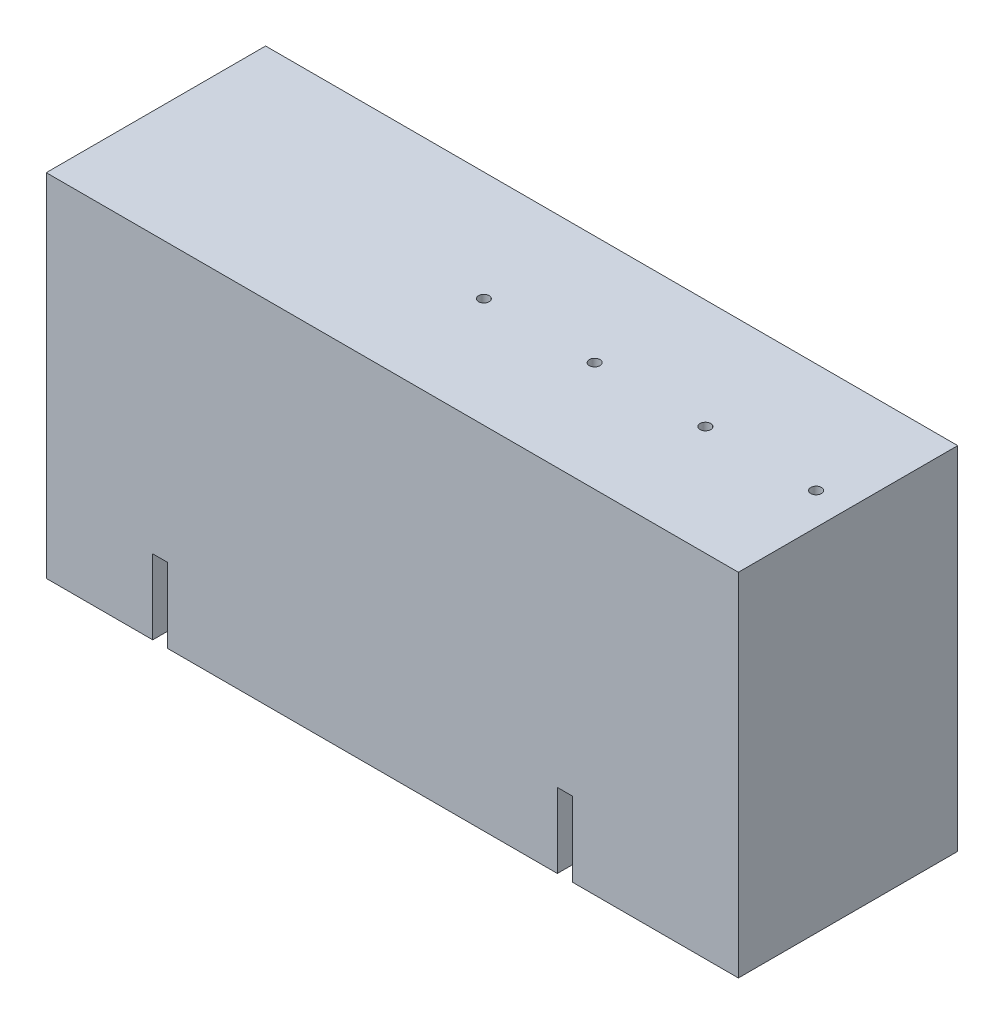
from build123d import *

# Parameters (mm, degrees)
SKETCH1_W             = 325
SKETCH1_H             = 103
BOSS_EXTRUDE1_DEPTH   = 165
M6_TAPPED_HOLE1_D     = 5
M6_TAPPED_HOLE1_DEPTH = 15
M6_TAPPED_HOLE1_TIP   = 1.502151548
CUT_EXTRUDE1_DEPTH    = 35


with BuildPart() as part:
    # Sketch1 → Boss-Extrude1 (new body)
    with BuildSketch(Plane(origin=(0, 0, 0), x_dir=(1, 0, 0), z_dir=(0, 1, 0))):
        with Locations((162.5, 51.5)):
            Rectangle(SKETCH1_W, SKETCH1_H)
    extrude(amount=BOSS_EXTRUDE1_DEPTH)

    # M6 Tapped Hole1
    with Locations(Plane(origin=(0, 165, 0), x_dir=(1, 0, 0), z_dir=(0, 1, 0))):
        with Locations((310, 51.5), (258, 51.5), (206, 51.5), (154, 51.5)):
            Hole(M6_TAPPED_HOLE1_D / 2, depth=M6_TAPPED_HOLE1_DEPTH)
            with Locations((0, 0, -(M6_TAPPED_HOLE1_DEPTH + M6_TAPPED_HOLE1_TIP / 2))):  # 118° drill point
                Cone(0, M6_TAPPED_HOLE1_D / 2, M6_TAPPED_HOLE1_TIP, mode=Mode.SUBTRACT)

    # Sketch5 → Cut-Extrude1 (cut)
    with BuildSketch(Plane.XZ):
        with BuildLine():
            Line((50, 0), (50, -11.5))
            ThreePointArc((50, -11.5), (53.5, -15), (57, -11.5))
            Line((57, -11.5), (57, 0))
            Line((57, 0), (50, 0))
        make_face()
        with BuildLine():
            Line((247, 0), (247, -11.5))
            ThreePointArc((247, -11.5), (243.5, -15), (240, -11.5))
            Line((240, -11.5), (240, 0))
            Line((240, 0), (247, 0))
        make_face()
        with BuildLine():
            Line((247, -103), (240, -103))
            Line((240, -103), (240, -91.5))
            ThreePointArc((240, -91.5), (243.5, -88), (247, -91.5))
            Line((247, -91.5), (247, -103))
        make_face()
        with BuildLine():
            Line((50, -103), (50, -91.5))
            ThreePointArc((50, -91.5), (53.5, -88), (57, -91.5))
            Line((57, -91.5), (57, -103))
            Line((57, -103), (50, -103))
        make_face()
    extrude(amount=-CUT_EXTRUDE1_DEPTH, mode=Mode.SUBTRACT)


solid = part.part
